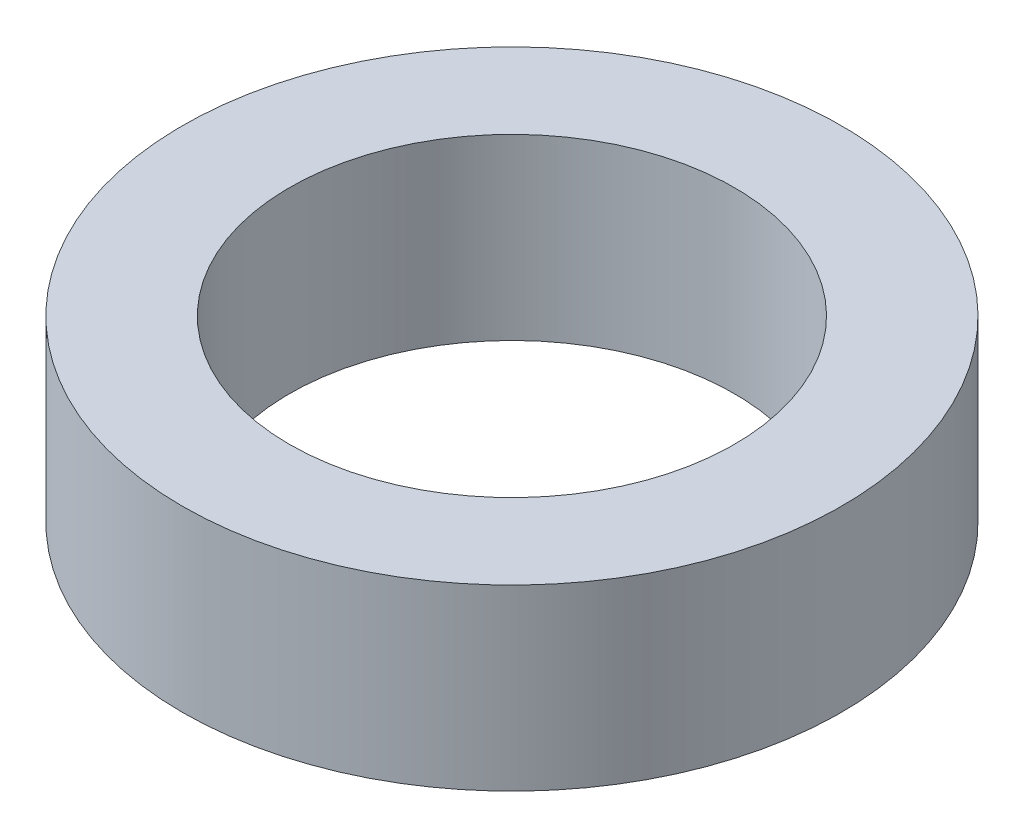
from build123d import *

# Parameters (mm, degrees)
SKETCH1_R           = 6
SKETCH1_R_2         = 4.05
BOSS_EXTRUDE1_DEPTH = 3.25


with BuildPart() as part:
    # Sketch1 → Boss-Extrude1 (new body)
    with BuildSketch(Plane(origin=(0, 0, 0), x_dir=(1, 0, 0), z_dir=(0, 1, 0))):
        Circle(SKETCH1_R)
        Circle(SKETCH1_R_2, mode=Mode.SUBTRACT)
    extrude(amount=BOSS_EXTRUDE1_DEPTH)


solid = part.part
